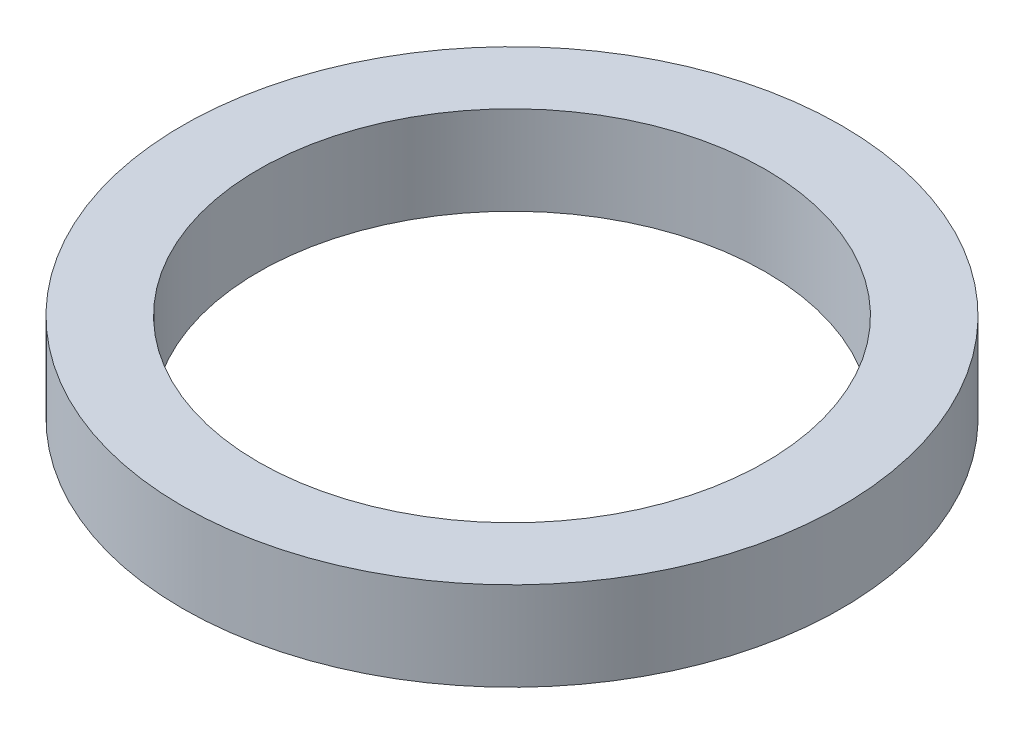
from build123d import *

# Parameters (mm, degrees)
SKETCH1_R           = 26
SKETCH1_R_2         = 20
BOSS_EXTRUDE1_DEPTH = 7


with BuildPart() as part:
    # Sketch1 → Boss-Extrude1 (new body)
    with BuildSketch(Plane(origin=(0, 0, 0), x_dir=(1, 0, 0), z_dir=(0, 1, 0))):
        Circle(SKETCH1_R)
        Circle(SKETCH1_R_2, mode=Mode.SUBTRACT)
    extrude(amount=BOSS_EXTRUDE1_DEPTH)


solid = part.part
